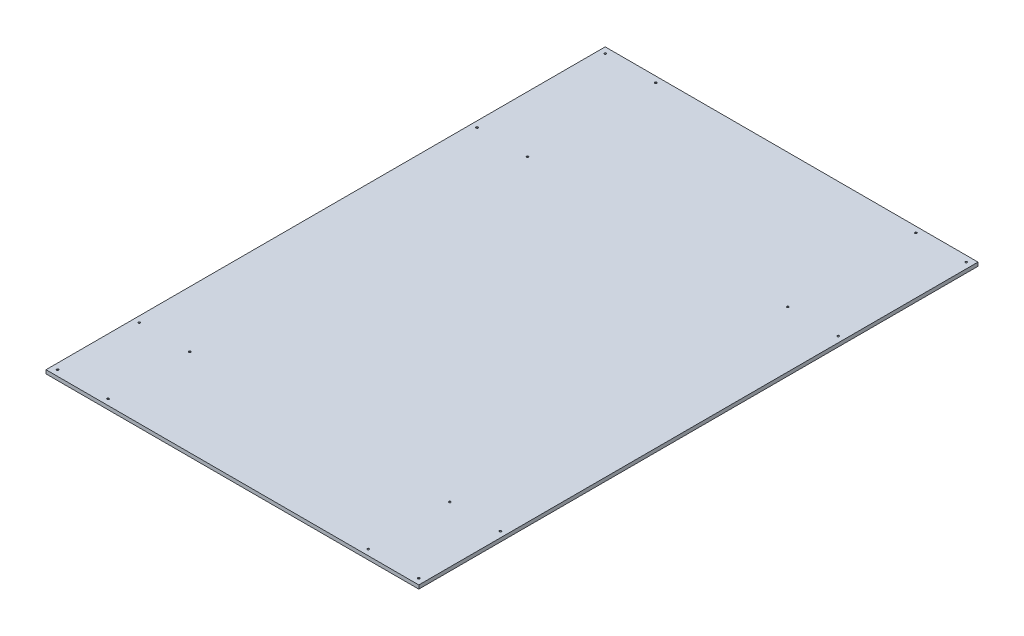
from build123d import *

# Parameters (mm, degrees)
SKETCH1_W                                 = 1219.2
SKETCH1_H                                 = 1828.8
BOSS_EXTRUDE1_DEPTH                       = 12
F_23_64_0_35938_DIAMETER_HOLE2_AT_2_COUNT = 2
F_23_64_0_35938_DIAMETER_HOLE2_AT_2_PITCH = 165.1
F_23_64_0_35938_DIAMETER_HOLE2_AT_3_COUNT = 2
F_23_64_0_35938_DIAMETER_HOLE2_AT_3_PITCH = 450.447355415
F_23_64_0_35938_DIAMETER_HOLE2_AT_4_COUNT = 2
F_23_64_0_35938_DIAMETER_HOLE2_AT_4_PITCH = 419.1
F_23_64_0_35938_DIAMETER_HOLE2_AT_5_COUNT = 2
F_23_64_0_35938_DIAMETER_HOLE2_AT_5_PITCH = 1524
F_23_64_0_35938_DIAMETER_HOLE2_AT_6_COUNT = 2
F_23_64_0_35938_DIAMETER_HOLE2_AT_6_PITCH = 1532.916830751
F_23_64_0_35938_DIAMETER_HOLE2_AT_7_COUNT = 2
F_23_64_0_35938_DIAMETER_HOLE2_AT_7_PITCH = 1798.29488683
F_23_64_0_35938_DIAMETER_HOLE2_AT_8_COUNT = 2
F_23_64_0_35938_DIAMETER_HOLE2_AT_8_PITCH = 1790.7


with BuildPart() as part:
    # Sketch1 → Boss-Extrude1 (new body)
    with BuildSketch(Plane(origin=(0, 0, 0), x_dir=(1, 0, 0), z_dir=(0, 1, 0))):
        Rectangle(SKETCH1_W, SKETCH1_H)
    extrude(amount=-BOSS_EXTRUDE1_DEPTH)

    # Sketch6 → 23_64 _0.35938_ Diameter Hole2 (revolve, cut)
    with BuildSketch(Plane(origin=(-590.55, 0, -895.35), x_dir=(0, 0, 1), z_dir=(1, 0, 0))):
        Polygon((0, 0), (0, 12), (3.2893, 12), (2.6543, 11.365), (2.6543, 0.635), (3.2893, 0), align=None)
    f_23_64_0_35938_diameter_hole2 = revolve(axis=Axis((-590.55, 6.35, -895.35), (0, -1, 0)), mode=Mode.SUBTRACT)

    # 23_64 _0.35938_ Diameter Hole2 at 2: 23_64 _0.35938_ Diameter Hole2 ×2
    with Locations(*[(i * F_23_64_0_35938_DIAMETER_HOLE2_AT_2_PITCH, 0, 0) for i in range(1, F_23_64_0_35938_DIAMETER_HOLE2_AT_2_COUNT)]):
        add(f_23_64_0_35938_diameter_hole2, mode=Mode.SUBTRACT)

    # 23_64 _0.35938_ Diameter Hole2 at 3: 23_64 _0.35938_ Diameter Hole2 ×2
    with Locations(*[Vector(0.3665245183824908, 0, 0.9304083928170915) * (i * F_23_64_0_35938_DIAMETER_HOLE2_AT_3_PITCH) for i in range(1, F_23_64_0_35938_DIAMETER_HOLE2_AT_3_COUNT)]):
        add(f_23_64_0_35938_diameter_hole2, mode=Mode.SUBTRACT)

    # 23_64 _0.35938_ Diameter Hole2 at 4: 23_64 _0.35938_ Diameter Hole2 ×2
    with Locations(*[(0, 0, i * F_23_64_0_35938_DIAMETER_HOLE2_AT_4_PITCH) for i in range(1, F_23_64_0_35938_DIAMETER_HOLE2_AT_4_COUNT)]):
        add(f_23_64_0_35938_diameter_hole2, mode=Mode.SUBTRACT)

    # 23_64 _0.35938_ Diameter Hole2 at 5: 23_64 _0.35938_ Diameter Hole2 ×2
    with Locations(*[(0, 0, i * F_23_64_0_35938_DIAMETER_HOLE2_AT_5_PITCH) for i in range(1, F_23_64_0_35938_DIAMETER_HOLE2_AT_5_COUNT)]):
        add(f_23_64_0_35938_diameter_hole2, mode=Mode.SUBTRACT)

    # 23_64 _0.35938_ Diameter Hole2 at 6: 23_64 _0.35938_ Diameter Hole2 ×2
    with Locations(*[Vector(0.1077031686833943, 0, 0.9941830955390242) * (i * F_23_64_0_35938_DIAMETER_HOLE2_AT_6_PITCH) for i in range(1, F_23_64_0_35938_DIAMETER_HOLE2_AT_6_COUNT)]):
        add(f_23_64_0_35938_diameter_hole2, mode=Mode.SUBTRACT)

    # 23_64 _0.35938_ Diameter Hole2 at 7: 23_64 _0.35938_ Diameter Hole2 ×2
    with Locations(*[Vector(0.09180919170103835, 0, 0.9957766176804926) * (i * F_23_64_0_35938_DIAMETER_HOLE2_AT_7_PITCH) for i in range(1, F_23_64_0_35938_DIAMETER_HOLE2_AT_7_COUNT)]):
        add(f_23_64_0_35938_diameter_hole2, mode=Mode.SUBTRACT)

    # 23_64 _0.35938_ Diameter Hole2 at 8: 23_64 _0.35938_ Diameter Hole2 ×2
    with Locations(*[(0, 0, i * F_23_64_0_35938_DIAMETER_HOLE2_AT_8_PITCH) for i in range(1, F_23_64_0_35938_DIAMETER_HOLE2_AT_8_COUNT)]):
        add(f_23_64_0_35938_diameter_hole2, mode=Mode.SUBTRACT)

    # Mirror1: 23_64 _0.35938_ Diameter Hole2 across plane
    add(f_23_64_0_35938_diameter_hole2.mirror(Plane(origin=(0, 0, 0), x_dir=(0, 0, 1), z_dir=(1, 0, 0))), mode=Mode.SUBTRACT)

    # Mirror1 copy 1 sketch → Mirror1 copy 1 (revolve, cut)
    with BuildSketch(Plane(origin=(425.45, 0, -895.35), x_dir=(0, 0, 1), z_dir=(-1, 0, 0))):
        Polygon((0, 0), (0, -12), (3.2893, -12), (2.6543, -11.365), (2.6543, -0.635), (3.2893, 0), align=None)
    revolve(axis=Axis((425.45, 6.35, -895.35), (0, 1, 0)), mode=Mode.SUBTRACT)

    # Mirror1 copy 2 sketch → Mirror1 copy 2 (revolve, cut)
    with BuildSketch(Plane(origin=(425.45, 0, -476.25), x_dir=(0, 0, 1), z_dir=(-1, 0, 0))):
        Polygon((0, 0), (0, -12), (3.2893, -12), (2.6543, -11.365), (2.6543, -0.635), (3.2893, 0), align=None)
    revolve(axis=Axis((425.45, 6.35, -476.25), (0, 1, 0)), mode=Mode.SUBTRACT)

    # Mirror1 copy 3 sketch → Mirror1 copy 3 (revolve, cut)
    with BuildSketch(Plane(origin=(590.55, 0, -476.25), x_dir=(0, 0, 1), z_dir=(-1, 0, 0))):
        Polygon((0, 0), (0, -12), (3.2893, -12), (2.6543, -11.365), (2.6543, -0.635), (3.2893, 0), align=None)
    revolve(axis=Axis((590.55, 6.35, -476.25), (0, 1, 0)), mode=Mode.SUBTRACT)

    # Mirror1 copy 4 sketch → Mirror1 copy 4 (revolve, cut)
    with BuildSketch(Plane(origin=(590.55, 0, 628.65), x_dir=(0, 0, 1), z_dir=(-1, 0, 0))):
        Polygon((0, 0), (0, -12), (3.2893, -12), (2.6543, -11.365), (2.6543, -0.635), (3.2893, 0), align=None)
    revolve(axis=Axis((590.55, 6.35, 628.65), (0, 1, 0)), mode=Mode.SUBTRACT)

    # Mirror1 copy 5 sketch → Mirror1 copy 5 (revolve, cut)
    with BuildSketch(Plane(origin=(425.45, 0, 628.65), x_dir=(0, 0, 1), z_dir=(-1, 0, 0))):
        Polygon((0, 0), (0, -12), (3.2893, -12), (2.6543, -11.365), (2.6543, -0.635), (3.2893, 0), align=None)
    revolve(axis=Axis((425.45, 6.35, 628.65), (0, 1, 0)), mode=Mode.SUBTRACT)

    # Mirror1 copy 6 sketch → Mirror1 copy 6 (revolve, cut)
    with BuildSketch(Plane(origin=(425.45, 0, 895.35), x_dir=(0, 0, 1), z_dir=(-1, 0, 0))):
        Polygon((0, 0), (0, -12), (3.2893, -12), (2.6543, -11.365), (2.6543, -0.635), (3.2893, 0), align=None)
    revolve(axis=Axis((425.45, 6.35, 895.35), (0, 1, 0)), mode=Mode.SUBTRACT)

    # Mirror1 copy 7 sketch → Mirror1 copy 7 (revolve, cut)
    with BuildSketch(Plane(origin=(590.55, 0, 895.35), x_dir=(0, 0, 1), z_dir=(-1, 0, 0))):
        Polygon((0, 0), (0, -12), (3.2893, -12), (2.6543, -11.365), (2.6543, -0.635), (3.2893, 0), align=None)
    revolve(axis=Axis((590.55, 6.35, 895.35), (0, 1, 0)), mode=Mode.SUBTRACT)


solid = part.part
